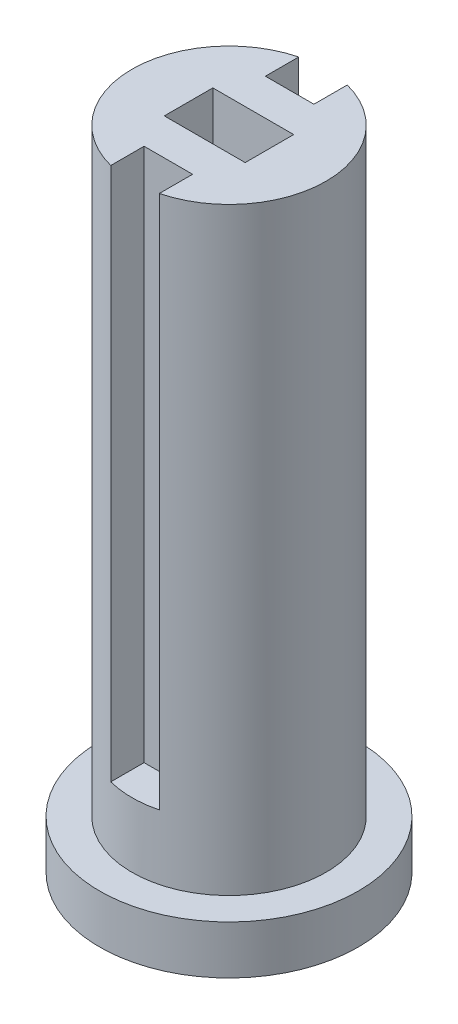
from build123d import *

# Parameters (mm, degrees)
ENL_V_MAT_EXTRU_4_DEPTH = 8
ENL_V_MAT_EXTRU_5_DEPTH = 33


with BuildPart() as part:
    # Esquisse4 → Révolution1 (revolve)
    with BuildSketch(Plane.XY):
        Polygon((-10.030612245, 30), (-10.030612245, -10), (-2.030612245, -10), (-2.030612245, -7), (-4.030612245, -7), (-4.030612245, 30), align=None)
    revolve(axis=Axis((-10.030612245, 30, 0), (0, -1, 0)))

    # Esquisse9 → Enlèv. mat.-Extru.4 (cut)
    with BuildSketch(Plane(origin=(0, 30, 0), x_dir=(1, 0, 0), z_dir=(0, 1, 0))):
        Polygon((-12.530612245, 1.5), (-7.530612245, 1.5), (-7.530612245, 0.5), (-7.530612245, -0.5), (-7.530612245, -1.5), (-12.530612245, -1.5), (-12.530612245, -0.5), (-12.530612245, 0.5), align=None)
    extrude(amount=-ENL_V_MAT_EXTRU_4_DEPTH, mode=Mode.SUBTRACT)

    # Esquisse11 → Enlèv. mat.-Extru.5 (cut)
    with BuildSketch(Plane(origin=(0, 30, 0), x_dir=(1, 0, 0), z_dir=(0, 1, 0))):
        Polygon((-10.030612245, 3.75), (-11.530612245, 3.75), (-11.530612245, 6.147265129), (-8.530612245, 6.147265129), (-8.530612245, 3.75), align=None)
        Polygon((-8.530612245, -3.75), (-10.030612245, -3.75), (-11.530612245, -3.75), (-11.530612245, -6.147265129), (-8.530612245, -6.147265129), align=None)
    extrude(amount=-ENL_V_MAT_EXTRU_5_DEPTH, mode=Mode.SUBTRACT)


solid = part.part
